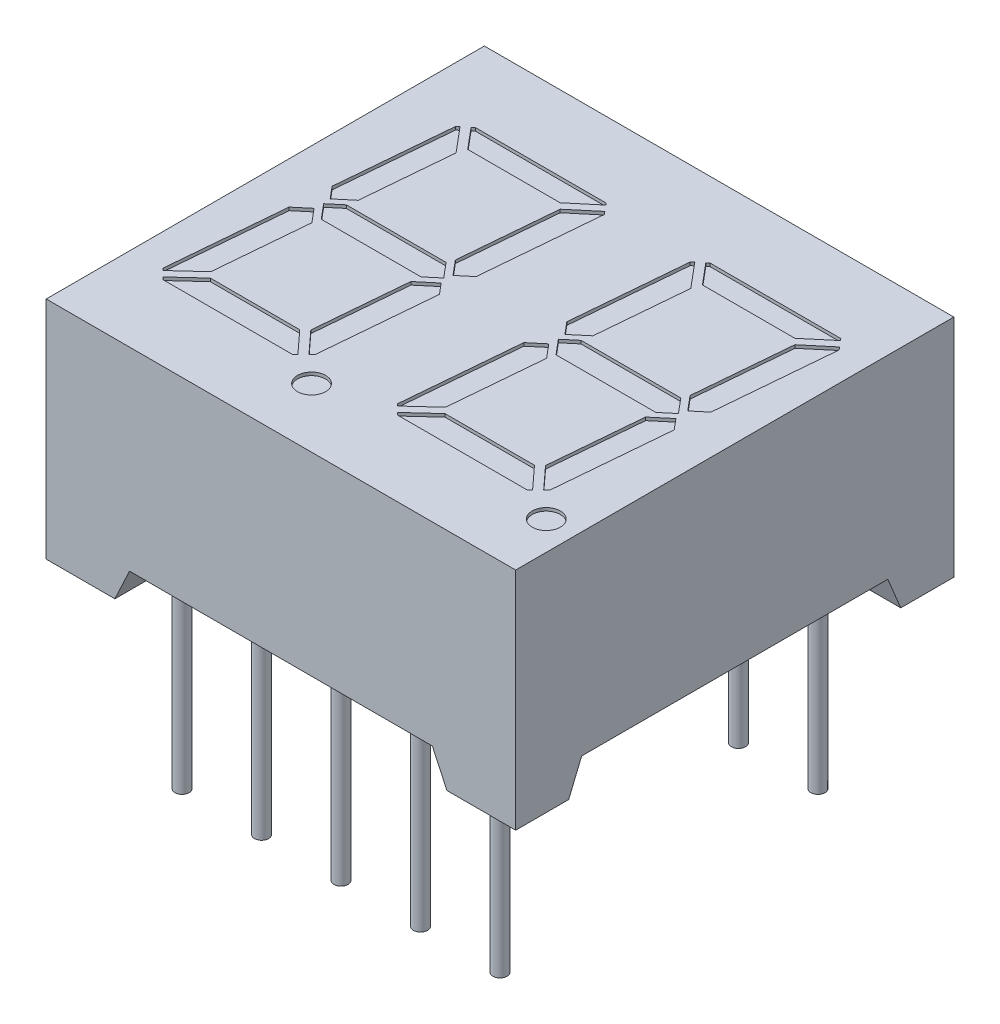
from build123d import *

# Parameters (mm, degrees)
SKETCH1_W               = 15
SKETCH1_H               = 14
EXTRUDE1_DEPTH          = 7.2
SKETCH6_R               = 0.45
CUT_EXTRUDE1_DEPTH      = 0.1
CUT_EXTRUDE2_DEPTH      = 1
CUT_EXTRUDE2_DEPTH_BACK = 16
CUT_EXTRUDE3_DEPTH      = 1
CUT_EXTRUDE3_DEPTH_BACK = 15
LPATTERN2_COUNT         = 2
LPATTERN2_PITCH         = 7.5
BOSS_EXTRUDE4_START     = -1
SKETCH11_R              = 0.225
BOSS_EXTRUDE4_DEPTH     = 7.1
LPATTERN3_COUNT         = 5
LPATTERN3_PITCH         = 2.54
LPATTERN3_COUNT_DIR2    = 2
LPATTERN3_PITCH_DIR2    = 10.16


with BuildPart() as part:
    # Sketch1 → Extrude1 (new body)
    with BuildSketch(Plane(origin=(0, 0, 0), x_dir=(1, 0, 0), z_dir=(0, 1, 0))):
        with Locations((-3.75, 0)):
            Rectangle(SKETCH1_W, SKETCH1_H)
    extrude(amount=-EXTRUDE1_DEPTH)

    # Sketch6 → Cut-Extrude1 (cut)
    with BuildSketch(Plane(origin=(0, 0, 0), x_dir=(-1, 0, 0), z_dir=(0, 1, 0))):
        with Locations((-2.828914589, 5.1)):
            Circle(SKETCH6_R)
        Polygon((1.615140342, 0.645647316), (1.874984591, 3.615680666), (2.672057265, 4.346063205), (2.736318521, 4.281801948), (2.412096101, 0.575922722), (1.978755924, 0.212307139), align=None)
        Polygon((-2.08510989, 4.246446609), (-2.404999919, 0.590086851), (-2.118563171, 0.248724827), (-1.593244842, 0.689519243), (-1.335889658, 3.631102448), (-1.988382771, 4.343173729), align=None)
        Polygon((-2.751982586, -4.346963991), (-2.828914589, -4.255280001), (-2.499336567, -0.488185972), (-2.097293847, -0.150832074), (-1.707416581, -0.615469707), (-1.976986224, -3.696664829), align=None)
        Polygon((-2.591285684, -4.538475102), (-1.79792785, -3.872768836), (1.154576659, -3.872768836), (1.713170541, -4.538475102), (1.639848023, -4.6), (-2.539660165, -4.6), align=None)
        Polygon((1.560181456, -0.4), (1.954104558, -0.069459271), (1.560181456, 0.4), (-1.627135675, 0.4), (-2.021058776, 0.069459271), (-1.627135675, -0.4), align=None)
        Polygon((2.495112157, 4.523008313), (2.41812047, 4.6), (-1.7315565, 4.6), (-1.811437663, 4.520118836), (-1.151570324, 3.8), (1.706087039, 3.8), align=None)
        Polygon((1.982853172, -0.306417777), (2.30166085, -0.686357973), (1.984568022, -4.310745576), (1.904681652, -4.377778199), (1.244483112, -3.590984217), (1.496113015, -0.714841264), align=None)
    cut_extrude1 = extrude(amount=-CUT_EXTRUDE1_DEPTH, mode=Mode.SUBTRACT)

    # Sketch12 → Cut-Extrude2 (cut, two sides)
    with BuildSketch(Plane.ZY.offset(11.25)) as cut_extrude2_sk:
        Polygon((-20.043427491, -42.781711537), (-5.305, -7.2), (-4.890786438, -6.2), (4.890786438, -6.2), (5.305, -7.2), (20.043427491, -42.781711537), (20.043427491, -119.808445619), (-20.043427491, -119.808445619), align=None)
    extrude(amount=CUT_EXTRUDE2_DEPTH, mode=Mode.SUBTRACT)
    extrude(cut_extrude2_sk.sketch, amount=-CUT_EXTRUDE2_DEPTH_BACK, mode=Mode.SUBTRACT)

    # Sketch13 → Cut-Extrude3 (cut, two sides)
    with BuildSketch(Plane(origin=(0, 0, -7), x_dir=(-1, 0, 0), z_dir=(0, 0, -1))) as cut_extrude3_sk:
        Polygon((-1.555, -7.2), (-1.088692342, -6.2), (8.588692342, -6.2), (9.055, -7.2), align=None)
    extrude(amount=CUT_EXTRUDE3_DEPTH, mode=Mode.SUBTRACT)
    extrude(cut_extrude3_sk.sketch, amount=-CUT_EXTRUDE3_DEPTH_BACK, mode=Mode.SUBTRACT)

    # LPattern2: Cut-Extrude1 ×2
    with Locations(*[(-i * LPATTERN2_PITCH, 0, 0) for i in range(1, LPATTERN2_COUNT)]):
        add(cut_extrude1, mode=Mode.SUBTRACT)

    # Sketch11 → Boss-Extrude4 (add)
    with BuildSketch(Plane.XZ.offset(7.2).offset(BOSS_EXTRUDE4_START)):
        with Locations((1.33, 5.08)):
            Circle(SKETCH11_R)
    boss_extrude4 = extrude(amount=BOSS_EXTRUDE4_DEPTH)

    # LPattern3: Boss-Extrude4 5 × 2
    with Locations(*[(-i * LPATTERN3_PITCH, 0, -j * LPATTERN3_PITCH_DIR2) for i in range(LPATTERN3_COUNT) for j in range(LPATTERN3_COUNT_DIR2) if (i, j) != (0, 0)]):
        add(boss_extrude4)


solid = part.part
